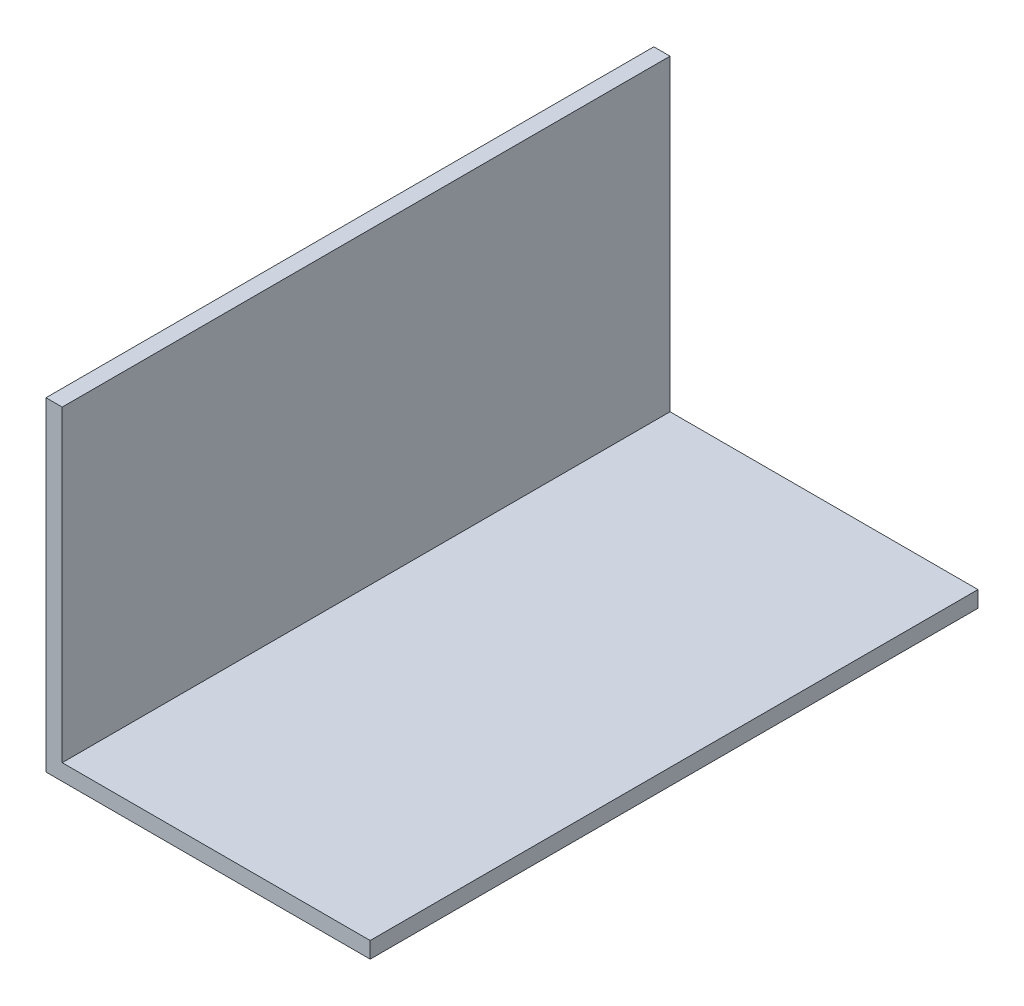
from build123d import *

# Parameters (mm, degrees)
SKETCH1_W           = 4
SKETCH1_H           = 76
SKETCH1_H_2         = 4
SKETCH1_W_2         = 76
BOSS_EXTRUDE1_DEPTH = 150


with BuildPart() as part:
    # Sketch1 → Boss-Extrude1 (new body)
    with BuildSketch(Plane.XY):
        with Locations((0, 2)):
            Rectangle(SKETCH1_W, SKETCH1_H)
        with Locations((0, -38)):
            Rectangle(SKETCH1_W, SKETCH1_H_2)
        with Locations((40, -38)):
            Rectangle(SKETCH1_W_2, SKETCH1_H_2)
    extrude(amount=BOSS_EXTRUDE1_DEPTH)


solid = part.part
